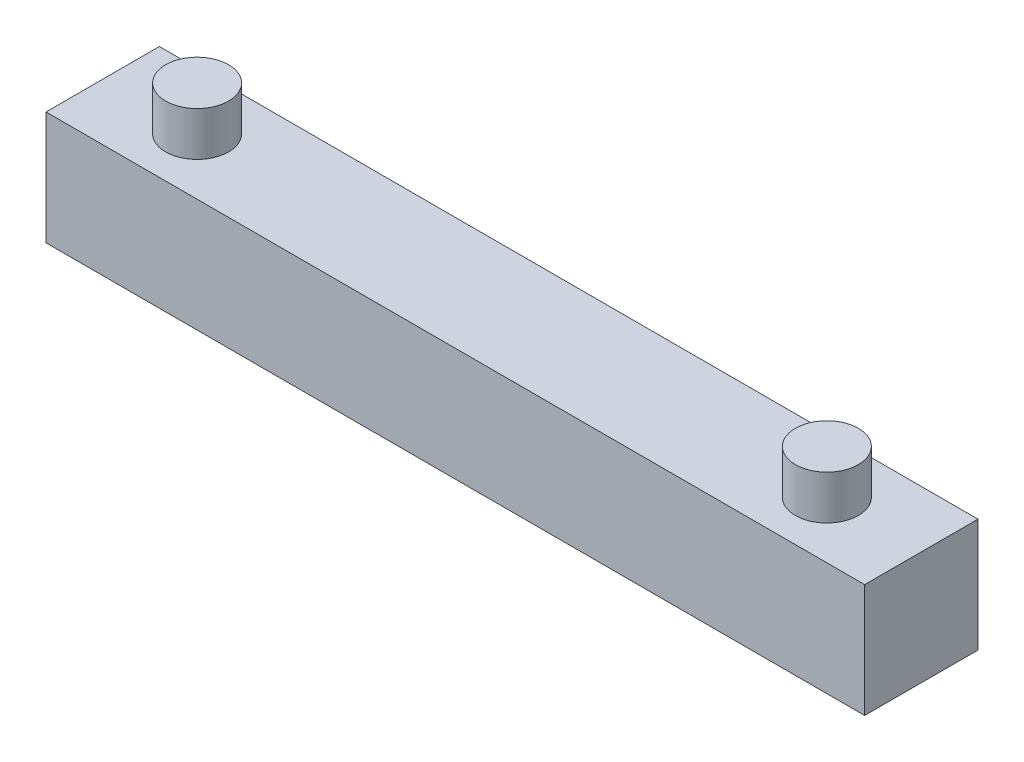
from build123d import *

# Parameters (mm, degrees)
SKETCH1_W           = 65
SKETCH1_H           = 9
BOSS_EXTRUDE1_DEPTH = 9
SKETCH2_R           = 2.5
BOSS_EXTRUDE2_DEPTH = 3.5


with BuildPart() as part:
    # Sketch1 → Boss-Extrude1 (new body)
    with BuildSketch(Plane(origin=(0, 0, 0), x_dir=(1, 0, 0), z_dir=(0, 1, 0))):
        with Locations((32.5, 4.5)):
            Rectangle(SKETCH1_W, SKETCH1_H)
    extrude(amount=BOSS_EXTRUDE1_DEPTH)

    # Sketch2 → Boss-Extrude2 (add)
    with BuildSketch(Plane(origin=(0, 9, 0), x_dir=(1, 0, 0), z_dir=(0, 1, 0))):
        with Locations(Location((7.5, 4.5, 0), (0, 0, 270))):  # turned: the seam where the file's is
            Circle(SKETCH2_R)
        with Locations(Location((57.5, 4.5, 0), (0, 0, 270))):  # turned: the seam where the file's is
            Circle(SKETCH2_R)
    extrude(amount=BOSS_EXTRUDE2_DEPTH)


solid = part.part
